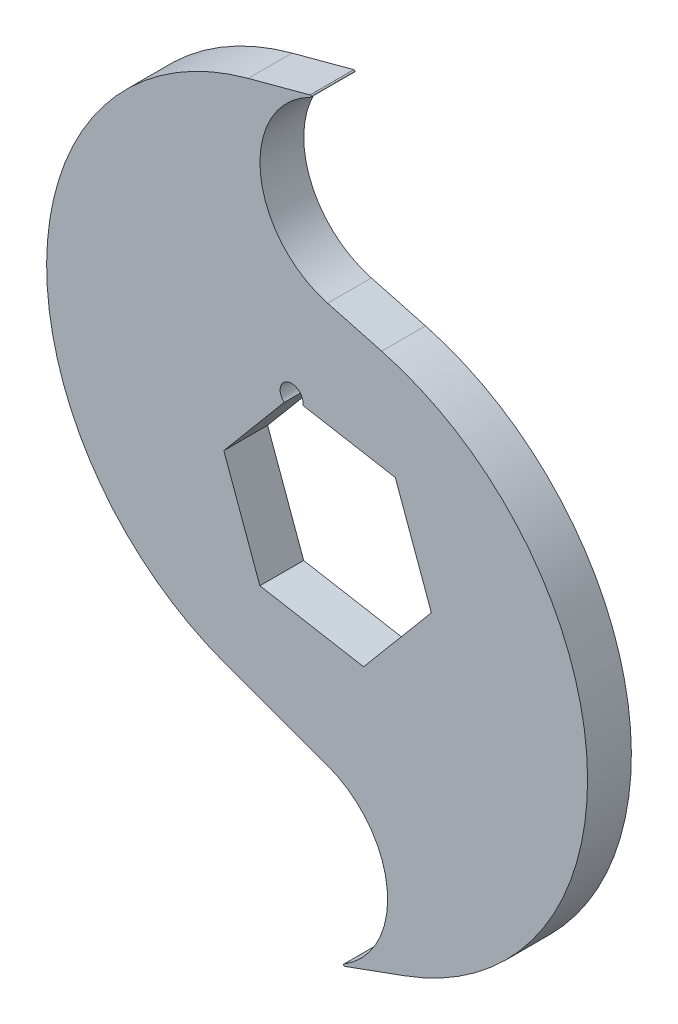
from build123d import *

# Parameters (mm, degrees)
BOSS_EXTRUDE1_DEPTH = 3.048
FILLET1_R           = 0.127


with BuildPart() as part:
    # Sketch1 → Boss-Extrude1 (new body, symmetric)
    with BuildSketch(Plane.XY):
        with BuildLine():
            ThreePointArc((0, 27.535484012), (-9.412998127, 39.802742006), (0, 52.07))
            Line((0, 52.07), (-11.040532194, 49.111698314))
            ThreePointArc((-11.040532194, 49.111698314), (-39.066320922, 14.192289272), (-14.190605813, -23.03684931))
            Line((-14.190605813, -23.03684931), (0, -28.201807432))
            ThreePointArc((0, -28.201807432), (8.35634418, -40.135903716), (0, -52.07))
            Line((0, -52.07), (10.740686656, -48.160709762))
            ThreePointArc((10.740686656, -48.160709762), (36.144496882, -10.141220984), (7.52373904, 25.519504212))
            Line((7.52373904, 25.519504212), (0, 27.535484012))
        make_face()
        with BuildLine():
            Line((-14.441907141, 2.546497882), (-6.036047045, 12.564211851))
            ThreePointArc((-6.036047045, 12.564211851), (-5.686528205, 15.219071016), (-3.428121714, 13.780307404))
            ThreePointArc((-3.428121714, 13.780307404), (-3.434162631, 13.641947663), (-3.452239406, 13.504640922))
            Line((-3.452239406, 13.504640922), (9.426285427, 11.233809522))
            Line((9.426285427, 11.233809522), (14.441907141, -2.546497882))
            Line((14.441907141, -2.546497882), (5.015621714, -13.780307404))
            Line((5.015621714, -13.780307404), (-9.426285427, -11.233809522))
            Line((-9.426285427, -11.233809522), (-14.441907141, 2.546497882))
        make_face(mode=Mode.SUBTRACT)
    extrude(amount=BOSS_EXTRUDE1_DEPTH, both=True)

    # Fillet1
    fillet1_edges = [part.edges().sort_by_distance(p)[0] for p in [
        (0, 52.07, 0),
        (0, -52.07, 0),
    ]]
    fillet(fillet1_edges, radius=FILLET1_R)


solid = part.part
